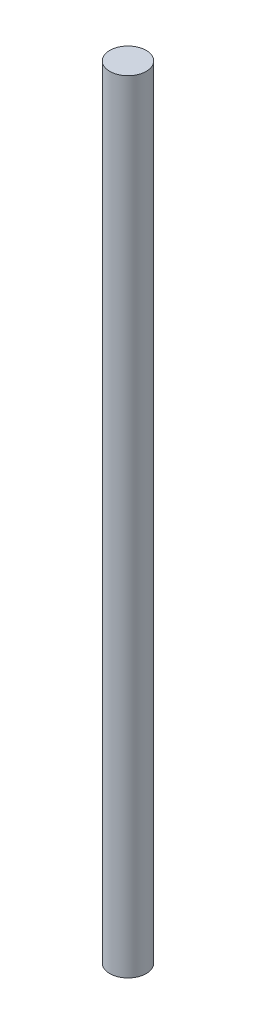
from build123d import *

# Parameters (mm, degrees)
SKETCH2_R           = 2.36855
BOSS_EXTRUDE1_DEPTH = 101.6


with BuildPart() as part:
    # Sketch2 → Boss-Extrude1 (new body)
    with BuildSketch(Plane(origin=(0, 0, 0), x_dir=(1, 0, 0), z_dir=(0, 1, 0))):
        Circle(SKETCH2_R)
    extrude(amount=BOSS_EXTRUDE1_DEPTH)


solid = part.part
